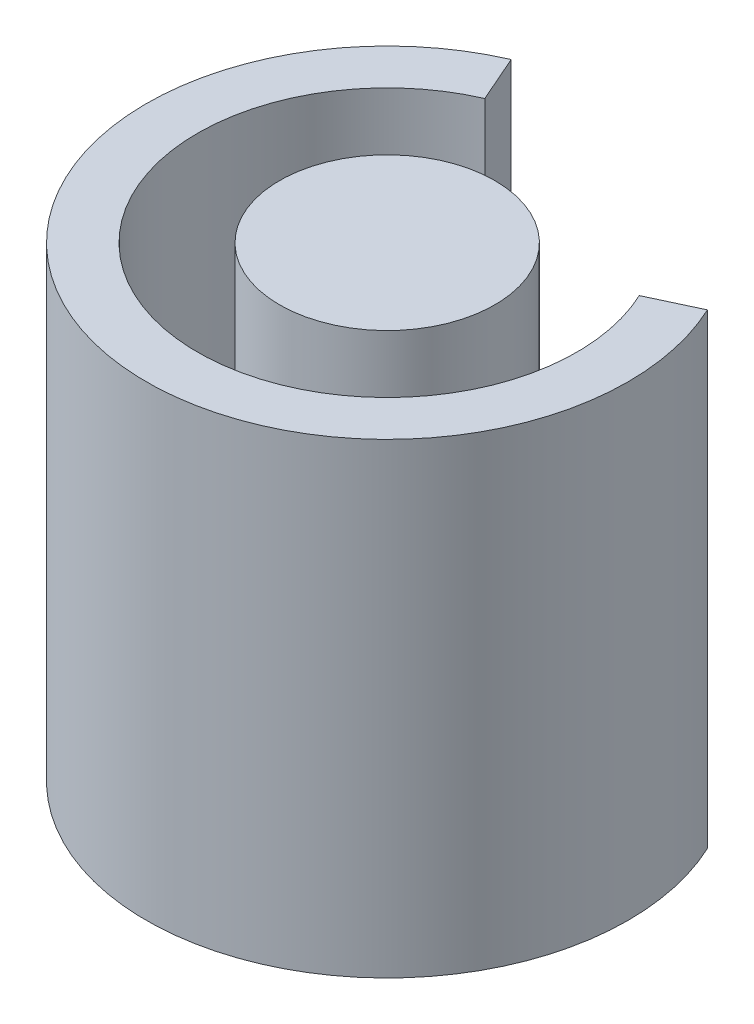
from build123d import *

# Parameters (mm, degrees)
EXTRUDE_THIN_START                         = 40.5
EXTRUDE_THIN_LIGHT_SENSOR_TUBE_DEPTH       = 9.1
BOSS_EXTRUDE_START                         = 40.5
LIGHT_SENSOR_TUBE_OUTLINE_3_R              = 2.1
BOSS_EXTRUDE_LIGHT_SENSOR_LIGHT_PIPE_DEPTH = 8.19


with BuildPart() as part:
    # Light sensor tube outline → Extrude-Thin light sensor tube (new body)
    with BuildSketch(Plane(origin=(0, 0, 0), x_dir=(1, 0, 0), z_dir=(0, 1, 0)).offset(EXTRUDE_THIN_START)):
        with BuildLine():
            ThreePointArc((-34.714683023, 28.659058324), (-34.535157443, 21.80783824), (-29.877535995, 26.83556223))
            Line((-29.877535995, 26.83556223), (-28.971464642, 27.258687157))
            ThreePointArc((-28.971464642, 27.258687157), (-34.887902697, 20.872118846), (-35.115948705, 29.575020033))
            Line((-35.115948705, 29.575020033), (-34.714683023, 28.659058324))
        make_face()
    extrude(amount=-EXTRUDE_THIN_LIGHT_SENSOR_TUBE_DEPTH)


with BuildPart() as body_2:
    # Light sensor tube outline_3 → Boss-Extrude light sensor light pipe (new body)
    with BuildSketch(Plane(origin=(0, 0, 0), x_dir=(1, 0, 0), z_dir=(0, 1, 0)).offset(BOSS_EXTRUDE_START)):
        with Locations((-33.23, 25.27)):
            Circle(LIGHT_SENSOR_TUBE_OUTLINE_3_R)
    extrude(amount=-BOSS_EXTRUDE_LIGHT_SENSOR_LIGHT_PIPE_DEPTH)


solid = Compound([part.part, body_2.part])
